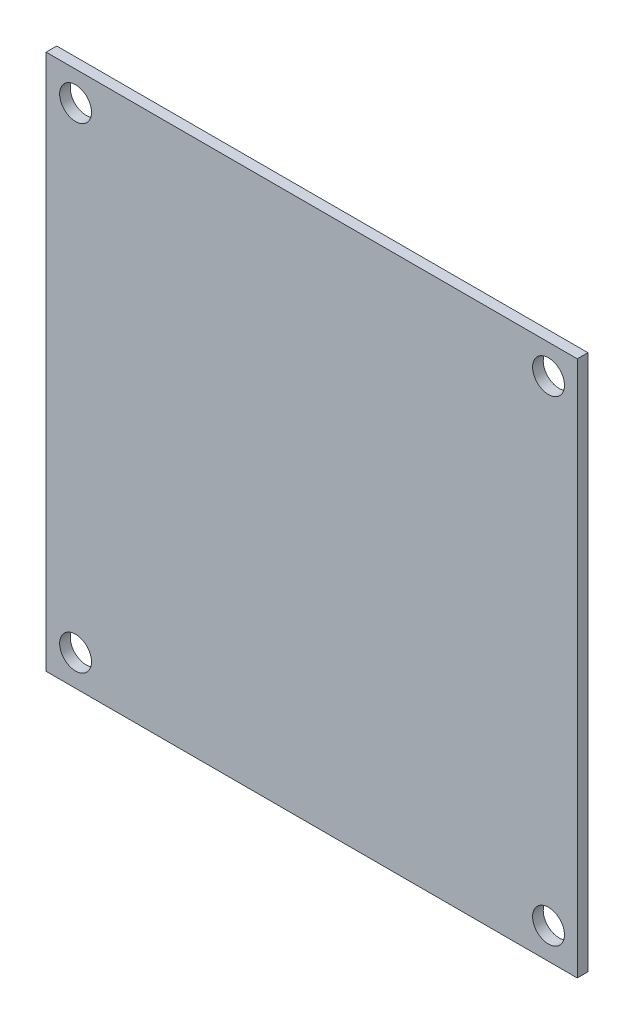
from build123d import *

# Parameters (mm, degrees)
SKETCH2_W           = 50
SKETCH2_H           = 80
BOSS_EXTRUDE1_DEPTH = 1
SKETCH3_W           = 50
SKETCH3_H           = 29.519153455
CUT_EXTRUDE1_DEPTH  = 1
SKETCH4_R           = 1.5
CUT_EXTRUDE2_DEPTH  = 1


with BuildPart() as part:
    # Sketch2 → Boss-Extrude1 (new body)
    with BuildSketch(Plane.XY):
        Rectangle(SKETCH2_W, SKETCH2_H)
    extrude(amount=BOSS_EXTRUDE1_DEPTH)

    # Sketch3 → Cut-Extrude1 (cut)
    with BuildSketch(Plane(origin=(0, 0, 0), x_dir=(-1, 0, 0), z_dir=(0, 0, -1))):
        with Locations((0, 25.240423272)):
            Rectangle(SKETCH3_W, SKETCH3_H)
    extrude(amount=-CUT_EXTRUDE1_DEPTH, mode=Mode.SUBTRACT)

    # Sketch4 → Cut-Extrude2 (cut)
    with BuildSketch(Plane(origin=(0, 0, 0), x_dir=(-1, 0, 0), z_dir=(0, 0, -1))):
        with Locations((-22.295607623, 7.7083308)):
            Circle(SKETCH4_R)
        with Locations((-22.295607623, -37.089644331)):
            Circle(SKETCH4_R)
        with Locations((22.226687661, 7.7083308)):
            Circle(SKETCH4_R)
        with Locations((22.226687661, -37.089644331)):
            Circle(SKETCH4_R)
    extrude(amount=-CUT_EXTRUDE2_DEPTH, mode=Mode.SUBTRACT)


solid = part.part
